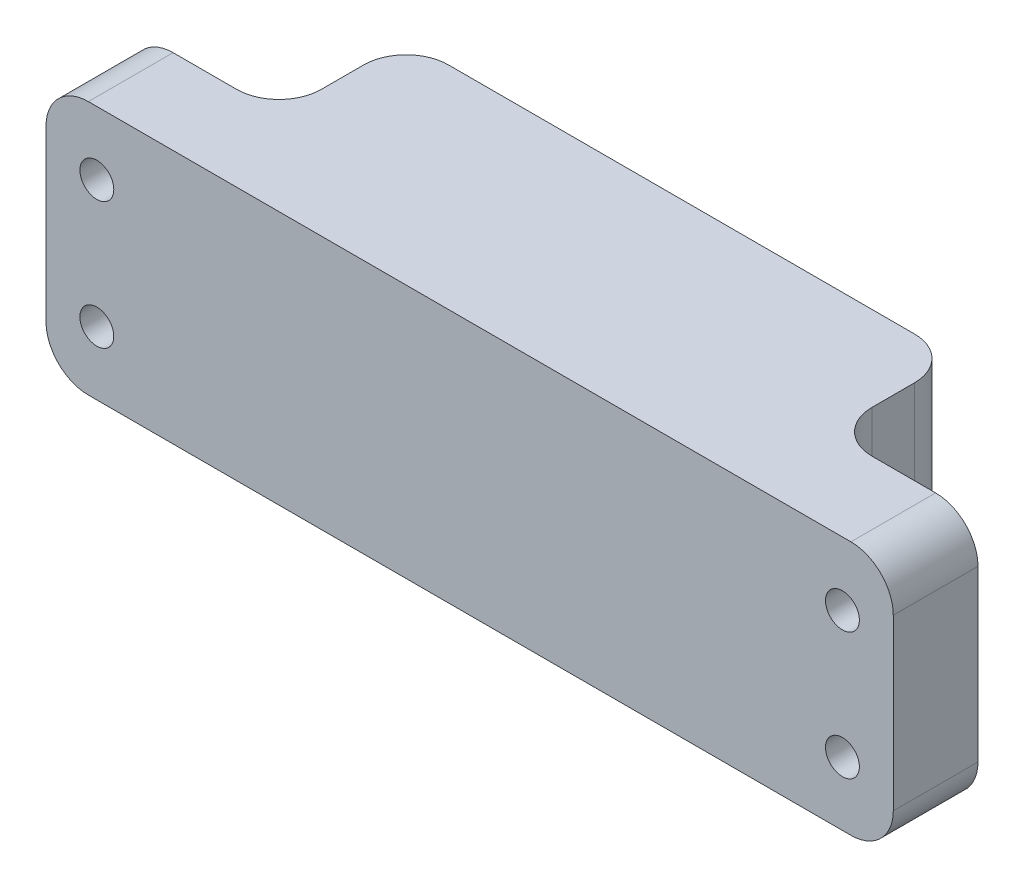
from build123d import *

# Parameters (mm, degrees)
BOSS_EXTRUDE1_DEPTH = 60
FILLET1_R           = 10
SKETCH2_R           = 4
CUT_EXTRUDE1_DEPTH  = 21
SKETCH3_R           = 6
SKETCH3_R_2         = 4
CUT_EXTRUDE2_DEPTH  = 10


with BuildPart() as part:
    # Sketch1 → Boss-Extrude1 (new body)
    with BuildSketch(Plane(origin=(0, 0, 0), x_dir=(1, 0, 0), z_dir=(0, 1, 0))):
        Polygon((-65, -5), (-100, -5), (-100, -25), (100, -25), (100, -5), (65, -5), (65, 25), (-65, 25), align=None)
    extrude(amount=BOSS_EXTRUDE1_DEPTH)

    # Fillet1
    fillet1_edges = [part.edges().sort_by_distance(p)[0] for p in [
        (-100, 0, 15),
        (-65, 30, 5),
        (-65, 30, -25),
        (65, 30, -25),
        (65, 30, 5),
        (-100, 60, 15),
        (100, 60, 15),
        (100, 0, 15),
    ]]
    fillet(fillet1_edges, radius=FILLET1_R)

    # Sketch2 → Cut-Extrude1 (cut, through all)
    with BuildSketch(Plane(origin=(0, 0, 5), x_dir=(-1, 0, 0), z_dir=(0, 0, -1))):
        with Locations((-88, 45)):
            Circle(SKETCH2_R)
        with Locations((-88, 15)):
            Circle(SKETCH2_R)
        with Locations((88, 15)):
            Circle(SKETCH2_R)
        with Locations((88, 45)):
            Circle(SKETCH2_R)
    extrude(amount=-CUT_EXTRUDE1_DEPTH, mode=Mode.SUBTRACT)

    # Sketch3 → Cut-Extrude2 (cut)
    with BuildSketch(Plane(origin=(0, 0, 5), x_dir=(-1, 0, 0), z_dir=(0, 0, -1))):
        with Locations((88, 15)):
            Circle(SKETCH3_R)
        with Locations((88, 15)):
            Circle(SKETCH3_R_2, mode=Mode.SUBTRACT)
        with Locations((88, 45)):
            Circle(SKETCH3_R)
        with Locations((88, 45)):
            Circle(SKETCH3_R_2, mode=Mode.SUBTRACT)
        with Locations((-88, 15)):
            Circle(SKETCH3_R)
        with Locations((-88, 15)):
            Circle(SKETCH3_R_2, mode=Mode.SUBTRACT)
        with Locations((-88, 45)):
            Circle(SKETCH3_R)
        with Locations((-88, 45)):
            Circle(SKETCH3_R_2, mode=Mode.SUBTRACT)
    extrude(amount=-CUT_EXTRUDE2_DEPTH, mode=Mode.SUBTRACT)


solid = part.part
